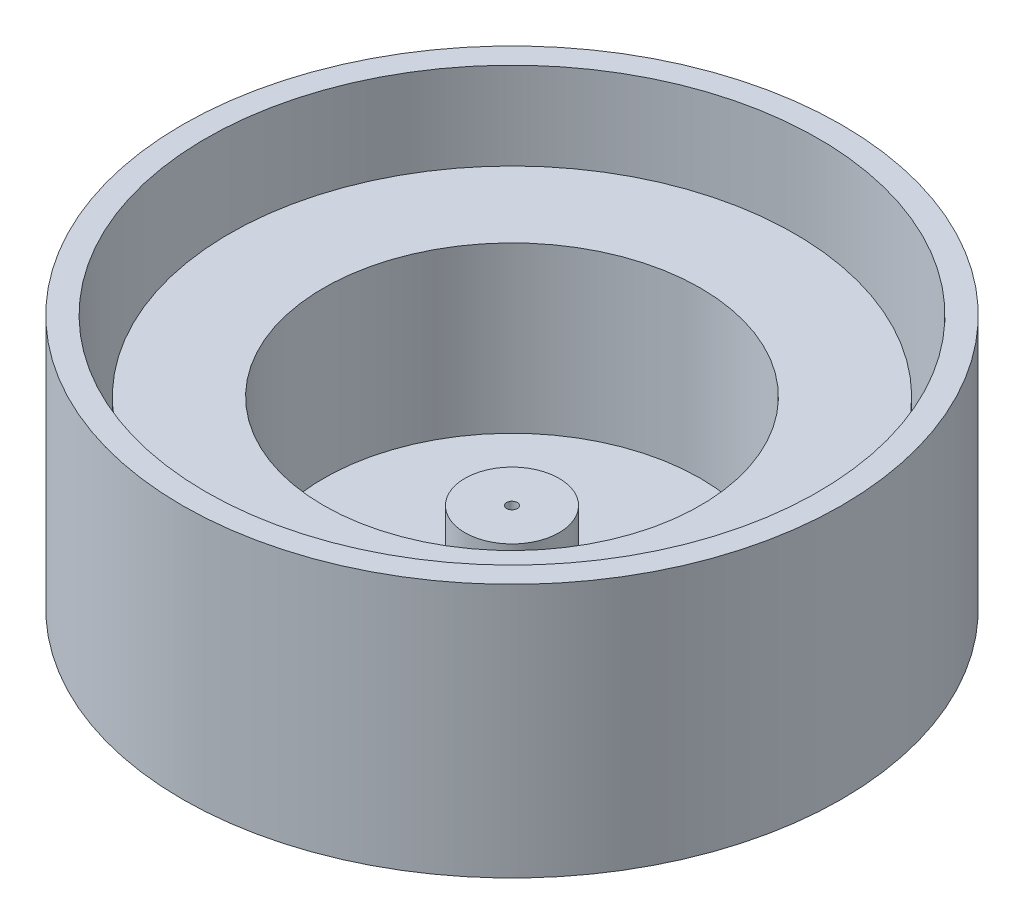
from build123d import *

# Parameters (mm, degrees)
SKETCH1_R           = 70
BOSS_EXTRUDE2_DEPTH = 4
SKETCH1_6_R         = 10
SKETCH1_6_R_2       = 1.125
BOSS_EXTRUDE3_DEPTH = 15
BOSS_EXTRUDE4_START = 50
SKETCH1_7_R         = 70
SKETCH1_7_R_2       = 65
BOSS_EXTRUDE4_DEPTH = 50
SKETCH1_8_R         = 60
SKETCH1_8_R_2       = 40
BOSS_EXTRUDE5_DEPTH = 35


with BuildPart() as part:
    # Sketch1 → Boss-Extrude2 (new body)
    with BuildSketch(Plane(origin=(0, 0, 0), x_dir=(1, 0, 0), z_dir=(0, 1, 0))):
        Circle(SKETCH1_R)
    extrude(amount=-BOSS_EXTRUDE2_DEPTH)

    # Sketch1_6 → Boss-Extrude3 (add)
    with BuildSketch(Plane(origin=(0, 0, 0), x_dir=(1, 0, 0), z_dir=(0, 1, 0))):
        Circle(SKETCH1_6_R)
        Circle(SKETCH1_6_R_2, mode=Mode.SUBTRACT)
    extrude(amount=BOSS_EXTRUDE3_DEPTH)

    # Sketch1_7 → Boss-Extrude4 (add)
    with BuildSketch(Plane(origin=(0, 0, 0), x_dir=(1, 0, 0), z_dir=(0, 1, 0)).offset(BOSS_EXTRUDE4_START)):
        Circle(SKETCH1_7_R)
        Circle(SKETCH1_7_R_2, mode=Mode.SUBTRACT)
    extrude(amount=-BOSS_EXTRUDE4_DEPTH)

    # Sketch1_8 → Boss-Extrude5 (add)
    with BuildSketch(Plane(origin=(0, 0, 0), x_dir=(1, 0, 0), z_dir=(0, 1, 0))):
        Circle(SKETCH1_8_R)
        Circle(SKETCH1_8_R_2, mode=Mode.SUBTRACT)
    extrude(amount=BOSS_EXTRUDE5_DEPTH)


solid = part.part
